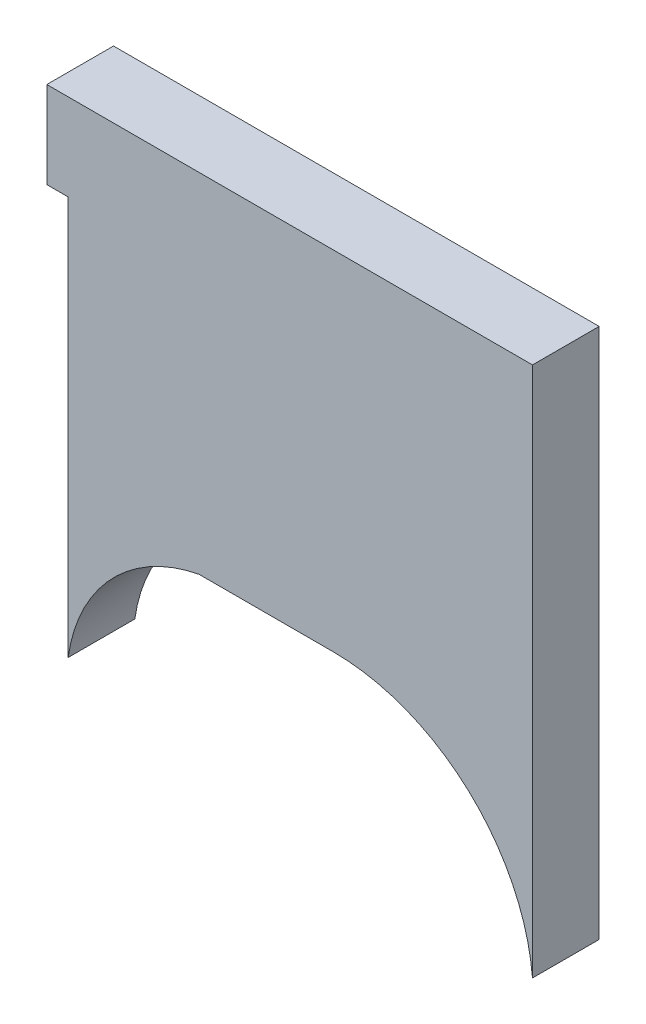
from build123d import *

# Parameters (mm, degrees)
BOSS_EXTRUDE3_DEPTH = 3.175


with BuildPart() as part:
    # Sketch3 → Boss-Extrude3 (new body)
    with BuildSketch(Plane.XY):
        with BuildLine():
            Line((30.293540828, -9.162699553), (26.82456956, -9.162699553))
            Line((26.82456956, -9.162699553), (23.910273162, -9.162699553))
            ThreePointArc((23.910273162, -9.162699553), (19.744450184, -11.435363695), (17.679624466, -15.708018391))
            Line((17.679624466, -15.708018391), (17.679624466, 3.279335675))
            Line((17.679624466, 3.279335675), (16.66456956, 3.279335675))
            Line((16.66456956, 3.279335675), (16.66456956, 7.406835675))
            Line((16.66456956, 7.406835675), (38.515978397, 7.406835675))
            Line((38.515978397, 7.406835675), (39.783204201, 7.406835675))
            Line((39.783204201, 7.406835675), (39.783204201, -6.622699553))
            Line((39.783204201, -6.622699553), (39.783204201, -9.162699553))
            Line((39.783204201, -9.162699553), (39.783204201, -17.86799591))
            ThreePointArc((39.783204201, -17.86799591), (36.732405161, -11.668678888), (30.293540828, -9.162699553))
        make_face()
    extrude(amount=BOSS_EXTRUDE3_DEPTH)


solid = part.part
